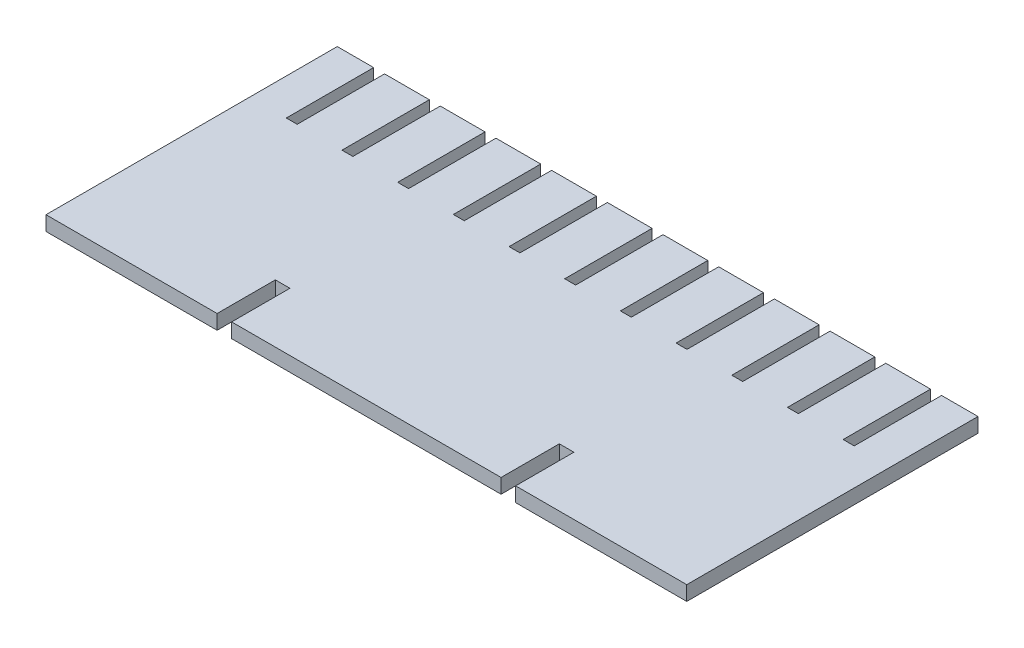
from build123d import *

# Parameters (mm, degrees)
BOSS_EXTRUDE1_DEPTH = 12.7


with BuildPart() as part:
    # Sketch1 → Boss-Extrude1 (new body)
    with BuildSketch(Plane(origin=(0, 0, 0), x_dir=(1, 0, 0), z_dir=(0, 1, 0))):
        Polygon((0, 0), (0, 254), (31.75, 254), (31.75, 177.8), (41.275, 177.8), (41.275, 254), (80.3148, 254), (80.3148, 177.8), (89.8398, 177.8), (89.8398, 254), (128.8796, 254), (128.8796, 177.8), (138.4046, 177.8), (138.4046, 254), (177.4444, 254), (177.4444, 177.8), (186.9694, 177.8), (186.9694, 254), (226.0092, 254), (226.0092, 177.8), (235.5342, 177.8), (235.5342, 254), (274.574, 254), (274.574, 177.8), (284.099, 177.8), (284.099, 254), (323.1388, 254), (323.1388, 177.8), (332.6638, 177.8), (332.6638, 254), (371.7036, 254), (371.7036, 177.8), (381.2286, 177.8), (381.2286, 254), (420.2684, 254), (420.2684, 177.8), (429.7934, 177.8), (429.7934, 254), (468.8332, 254), (468.8332, 177.8), (478.3582, 177.8), (478.3582, 254), (517.398, 254), (517.398, 177.8), (527.05, 177.8), (527.05, 254), (558.8, 254), (558.8, 0), (409.575, 0), (409.575, 50.8), (396.875, 50.8), (396.875, 0), (161.925, 0), (161.925, 50.8), (149.225, 50.8), (149.225, 0), align=None)
    extrude(amount=BOSS_EXTRUDE1_DEPTH)


solid = part.part
